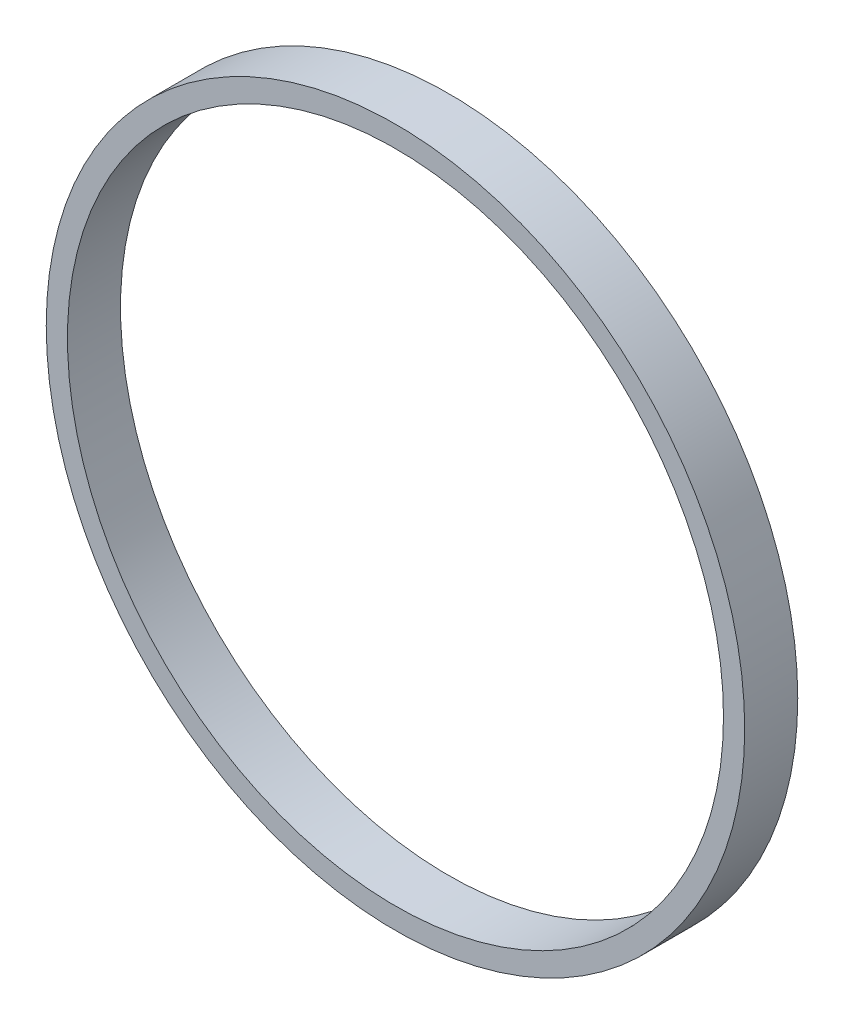
from build123d import *

# Parameters (mm, degrees)
SKETCH2_R           = 41.7957
SKETCH2_R_2         = 39.2557
BOSS_EXTRUDE1_DEPTH = 6.35


with BuildPart() as part:
    # Sketch2 → Boss-Extrude1 (new body)
    with BuildSketch(Plane.XY):
        Circle(SKETCH2_R)
        Circle(SKETCH2_R_2, mode=Mode.SUBTRACT)
    extrude(amount=BOSS_EXTRUDE1_DEPTH)


solid = part.part
